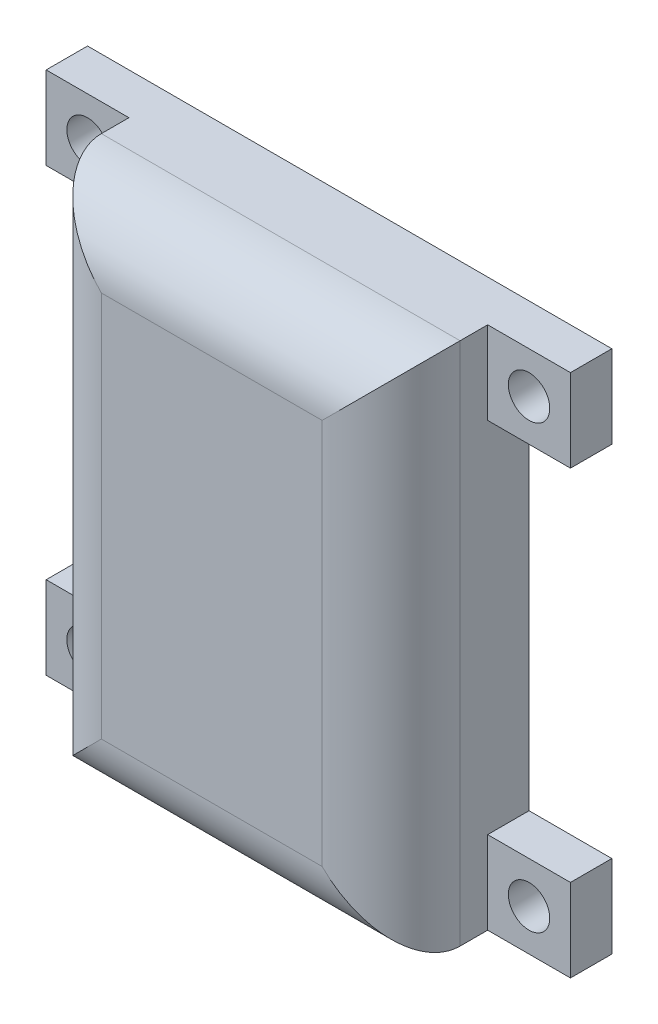
from build123d import *

# Parameters (mm, degrees)
SKETCH_1_W          = 26
SKETCH_1_H          = 38
EXTRUDE_1_DEPTH     = 10
SKETCH_2_W          = 22
SKETCH_2_H          = 34
CUT_EXTRUDE_1_DEPTH = 8
SKETCH_4_W          = 6
SKETCH_4_H          = 6
EXTRUDE_2_DEPTH     = 3
SKETCH_5_R          = 1.5
CUT_EXTRUDE_4_DEPTH = 11
FILLET_1_R          = 5


with BuildPart() as part:
    # ｽｹｯﾁ1 → ﾎﾞｽ - 押し出し1 (new body)
    with BuildSketch(Plane.XY):
        Rectangle(SKETCH_1_W, SKETCH_1_H)
    extrude(amount=EXTRUDE_1_DEPTH)

    # ｽｹｯﾁ2 → ｶｯﾄ - 押し出し1 (cut)
    with BuildSketch(Plane.XY):
        Rectangle(SKETCH_2_W, SKETCH_2_H)
    extrude(amount=CUT_EXTRUDE_1_DEPTH, mode=Mode.SUBTRACT)

    # ｽｹｯﾁ4 → ﾎﾞｽ - 押し出し2 (add)
    with BuildSketch(Plane.XY):
        with Locations((16, 16)):
            Rectangle(SKETCH_4_W, SKETCH_4_H)
        with Locations((16, -16)):
            Rectangle(SKETCH_4_W, SKETCH_4_H)
        with Locations((-16, -16)):
            Rectangle(SKETCH_4_W, SKETCH_4_H)
        with Locations((-16, 16)):
            Rectangle(SKETCH_4_W, SKETCH_4_H)
    extrude(amount=EXTRUDE_2_DEPTH)

    # ｽｹｯﾁ5 → ｶｯﾄ - 押し出し4 (cut, through all)
    with BuildSketch(Plane.XY):
        with Locations((-16, 16)):
            Circle(SKETCH_5_R)
        with Locations((-16, -16)):
            Circle(SKETCH_5_R)
        with Locations((16, -16)):
            Circle(SKETCH_5_R)
        with Locations((16, 16)):
            Circle(SKETCH_5_R)
    extrude(amount=CUT_EXTRUDE_4_DEPTH, mode=Mode.SUBTRACT)

    # ﾌｨﾚｯﾄ1
    fillet_1_edges = [part.edges().sort_by_distance(p)[0] for p in [
        (0, 19, 10),
        (0, -19, 10),
        (13, 0, 10),
        (-13, 0, 10),
    ]]
    fillet(fillet_1_edges, radius=FILLET_1_R)


solid = part.part
